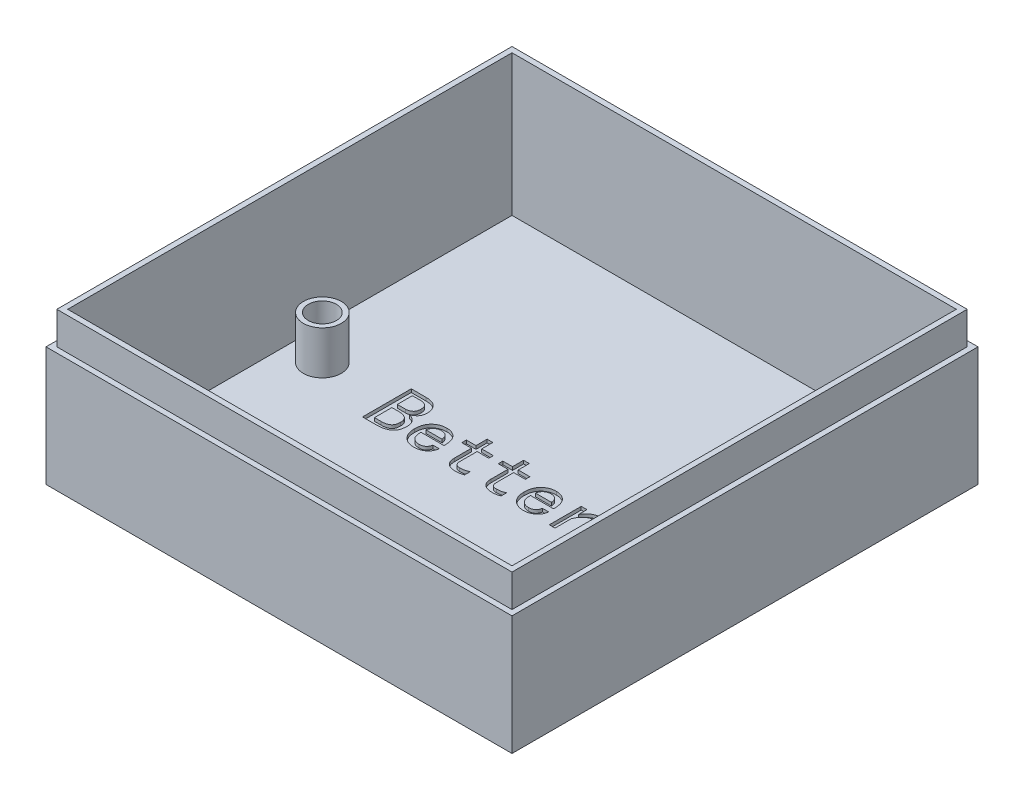
from build123d import *

# Parameters (mm, degrees)
SKETCH_1_W          = 43
SKETCH_1_H          = 43
EXTRUDE_1_DEPTH     = 14
SKETCH_2_W          = 41
SKETCH_2_H          = 41
CUT_EXTRUDE_1_DEPTH = 13
SKETCH_3_R          = 1.75
EXTRUDE_2_DEPTH     = 4
CUT_EXTRUDE_2_DEPTH = 0.3
SKETCH_6_W          = 43
SKETCH_6_H          = 43
SKETCH_6_W_2        = 42
SKETCH_6_H_2        = 42
CUT_EXTRUDE_3_DEPTH = 3
SKETCH_4_R          = 1.3
CUT_EXTRUDE_4_DEPTH = 6
SKETCH_9_R          = 1.55
CUT_EXTRUDE_5_DEPTH = 3


with BuildPart() as part:
    # 草图1 → 凸台-拉伸1 (new body)
    with BuildSketch(Plane(origin=(0, 0, 0), x_dir=(1, 0, 0), z_dir=(0, 1, 0))):
        with Locations((-5.509070295, -3.928571429)):
            Rectangle(SKETCH_1_W, SKETCH_1_H)
    extrude(amount=EXTRUDE_1_DEPTH)

    # 草图2 → 切除-拉伸1 (cut)
    with BuildSketch(Plane(origin=(0, 14, 0), x_dir=(1, 0, 0), z_dir=(0, 1, 0))):
        with Locations((-5.509070295, -3.928571429)):
            Rectangle(SKETCH_2_W, SKETCH_2_H)
    extrude(amount=-CUT_EXTRUDE_1_DEPTH, mode=Mode.SUBTRACT)

    # 草图3 → 凸台-拉伸2 (add)
    with BuildSketch(Plane(origin=(0, 1, 0), x_dir=(1, 0, 0), z_dir=(0, 1, 0))):
        with Locations((11.990929705, -20.428571429)):
            Circle(SKETCH_3_R)
        with Locations((11.990929705, 12.571428571)):
            Circle(SKETCH_3_R)
        with Locations((-23.009070295, -3.928571429)):
            Circle(SKETCH_3_R)
    extrude(amount=EXTRUDE_2_DEPTH)

    # 草图5 → 切除-拉伸2 (cut)
    with BuildSketch(Plane(origin=(0, 1, 0), x_dir=(1, 0, 0), z_dir=(0, 1, 0))):
        with BuildLine():
            add(Edge.make_bspline(
                [(-13.98754201, -5.087554235), (-13.98884355, -5.148684306), (-13.991349927, -5.266402496), (-14.010622519, -5.435807915), (-14.043382854, -5.590300694), (-14.089073364, -5.73054622), (-14.148335059, -5.855927811), (-14.221057431, -5.966926742), (-14.307645803, -6.062539103), (-14.40762424, -6.142749943), (-14.517215749, -6.210197735), (-14.634014643, -6.26911982), (-14.75832227, -6.3187478), (-14.889912901, -6.3597658), (-15.029189181, -6.390722201), (-15.175406971, -6.412856786), (-15.329053545, -6.426824846), (-15.433905332, -6.428700177), (-15.48754201, -6.429659498)],
                knots=[0, 0, 0, 0, 0.000183363, 0.000353102, 0.000510623, 0.000656409, 0.000794608, 0.000925445, 0.001053095, 0.001179894, 0.001308623, 0.001438516, 0.001571906, 0.001709706, 0.001851578, 0.001999485, 0.002153114, 0.002314006, 0.002314006, 0.002314006, 0.002314006], degree=3))
            Line((-15.48754201, -6.429659498), (-16.803331483, -6.429659498))
            Line((-16.803331483, -6.429659498), (-16.803331483, -1.929659498))
            Line((-16.803331483, -1.929659498), (-15.434910431, -1.929659498))
            add(Edge.make_bspline(
                [(-15.434910431, -1.929659498), (-15.381897455, -1.930334081), (-15.278841151, -1.931645459), (-15.1294118, -1.949270767), (-14.989442246, -1.974270777), (-14.860421537, -2.012845972), (-14.741487714, -2.06024041), (-14.632892999, -2.119075673), (-14.535272535, -2.189847869), (-14.44729276, -2.269646129), (-14.371091826, -2.357804477), (-14.303121887, -2.449246023), (-14.246336695, -2.545760096), (-14.19912939, -2.645676073), (-14.164325435, -2.750656088), (-14.137497473, -2.85902111), (-14.121712404, -2.97207885), (-14.119989651, -3.048845042), (-14.119120957, -3.087554235)],
                knots=[0, 0, 0, 0, 0.000158944, 0.000308985, 0.000450823, 0.000584976, 0.000712213, 0.000834338, 0.000954438, 0.001073107, 0.001189826, 0.001303477, 0.001414469, 0.001525224, 0.001634334, 0.001745676, 0.001859806, 0.001975893, 0.001975893, 0.001975893, 0.001975893], degree=3))
            add(Edge.make_bspline(
                [(-14.119120957, -3.087554235), (-14.120030688, -3.12557802), (-14.121798749, -3.199477121), (-14.130772974, -3.306499145), (-14.148851688, -3.405767422), (-14.172153149, -3.497609689), (-14.205402132, -3.580917708), (-14.242375823, -3.657742544), (-14.289158576, -3.72567003), (-14.358304515, -3.804134626), (-14.451666074, -3.887257938), (-14.565448223, -3.973217371), (-14.68213954, -4.041176882), (-14.763555436, -4.072332862), (-14.803331483, -4.087554235)],
                knots=[0, 0, 0, 0, 0.000114102, 0.000221756, 0.000321748, 0.000416551, 0.000505421, 0.000590418, 0.000671789, 0.000751925, 0.000903702, 0.001045809, 0.001179394, 0.001307, 0.001307, 0.001307, 0.001307], degree=3))
            add(Edge.make_bspline(
                [(-14.803331483, -4.087554235), (-14.751380449, -4.102485839), (-14.647372946, -4.132379351), (-14.501415957, -4.207326369), (-14.362451056, -4.300175579), (-14.256391256, -4.395344282), (-14.178464593, -4.480930903), (-14.127502096, -4.552062355), (-14.08334729, -4.627799805), (-14.048158958, -4.70972713), (-14.020974861, -4.796645961), (-14.001523002, -4.888993824), (-13.989672475, -4.986529706), (-13.988262122, -5.053407233), (-13.98754201, -5.087554235)],
                knots=[0, 0, 0, 0, 0.00016182, 0.000323968, 0.000489677, 0.000662244, 0.000749904, 0.000836468, 0.000924236, 0.001012414, 0.00110335, 0.001197019, 0.001295184, 0.001397597, 0.001397597, 0.001397597, 0.001397597], degree=3))
        make_face()
        with BuildLine():
            add(Edge.make_bspline(
                [(-14.724384115, -3.087554235), (-14.724810731, -3.059904139), (-14.725636764, -3.006366773), (-14.735798729, -2.929102668), (-14.75108149, -2.857558191), (-14.772591519, -2.791884816), (-14.799623677, -2.731545413), (-14.834562009, -2.677760194), (-14.874006233, -2.628163012), (-14.93746519, -2.573217584), (-15.024953535, -2.514738638), (-15.142551986, -2.464695487), (-15.271949658, -2.434693204), (-15.361969436, -2.43137707), (-15.408594641, -2.429659498)],
                knots=[0, 0, 0, 0, 8.2898e-05, 0.00016051, 0.000233349, 0.000302082, 0.0003675, 0.00043104, 0.000494062, 0.000556873, 0.000682032, 0.000808219, 0.000938255, 0.001077972, 0.001077972, 0.001077972, 0.001077972], degree=3))
            Line((-15.408594641, -2.429659498), (-16.198068325, -2.429659498))
            Line((-16.198068325, -2.429659498), (-16.198068325, -3.82439634))
            Line((-16.198068325, -3.82439634), (-15.434910431, -3.82439634))
            add(Edge.make_bspline(
                [(-15.434910431, -3.82439634), (-15.388253245, -3.82244374), (-15.296701688, -3.818612313), (-15.164836669, -3.785288076), (-15.042449003, -3.732128672), (-14.950014888, -3.669549828), (-14.884190113, -3.608193947), (-14.840390178, -3.554752289), (-14.80441103, -3.493788747), (-14.775381508, -3.425796976), (-14.7516355, -3.351152454), (-14.735682364, -3.2694033), (-14.725628728, -3.180724839), (-14.724809829, -3.119422836), (-14.724384115, -3.087554235)],
                knots=[0, 0, 0, 0, 0.000139788, 0.000274294, 0.000405222, 0.000538497, 0.000606758, 0.00067465, 0.000745021, 0.000818354, 0.000896034, 0.000979565, 0.001067824, 0.001163385, 0.001163385, 0.001163385, 0.001163385], degree=3))
        make_face(mode=Mode.SUBTRACT)
        with BuildLine():
            add(Edge.make_bspline(
                [(-14.619120957, -5.087554235), (-14.619616443, -5.053706), (-14.620573798, -4.988306074), (-14.635030186, -4.894381754), (-14.655793838, -4.8078191), (-14.686221789, -4.729157845), (-14.724980326, -4.658138656), (-14.773980418, -4.596311131), (-14.829700112, -4.540332715), (-14.917523183, -4.479679032), (-15.036309023, -4.417708641), (-15.188124834, -4.363444255), (-15.348360533, -4.330325538), (-15.458145117, -4.326392334), (-15.513857799, -4.32439634)],
                knots=[0, 0, 0, 0, 0.000101439, 0.000195996, 0.000284406, 0.000368028, 0.000448306, 0.000526096, 0.000603977, 0.000684308, 0.000845186, 0.001004569, 0.001166661, 0.001333672, 0.001333672, 0.001333672, 0.001333672], degree=3))
            Line((-15.513857799, -4.32439634), (-16.198068325, -4.32439634))
            Line((-16.198068325, -4.32439634), (-16.198068325, -5.929659498))
            Line((-16.198068325, -5.929659498), (-15.592805167, -5.929659498))
            add(Edge.make_bspline(
                [(-15.592805167, -5.929659498), (-15.554454315, -5.929115355), (-15.479920963, -5.928057835), (-15.371804737, -5.919428871), (-15.270737963, -5.90431485), (-15.17613803, -5.886037627), (-15.089227008, -5.858801722), (-15.00848334, -5.828728658), (-14.936224418, -5.789462415), (-14.868842498, -5.74742528), (-14.80952055, -5.695983247), (-14.758205349, -5.635384668), (-14.714431489, -5.56624811), (-14.679064414, -5.487770467), (-14.651953578, -5.400342712), (-14.633026472, -5.303947356), (-14.621078093, -5.198638944), (-14.619791272, -5.125600515), (-14.619120957, -5.087554235)],
                knots=[0, 0, 0, 0, 0.000115047, 0.000223589, 0.000325038, 0.000421569, 0.000512217, 0.000598009, 0.000679537, 0.000758479, 0.000835865, 0.000913989, 0.000995919, 0.001080535, 0.001171471, 0.001269911, 0.001374854, 0.001488955, 0.001488955, 0.001488955, 0.001488955], degree=3))
        make_face(mode=Mode.SUBTRACT)
        with BuildLine():
            add(Edge.make_bspline(
                [(-10.724384115, -5.429659498), (-10.729879058, -5.468441298), (-10.740638203, -5.544376384), (-10.768150301, -5.654910407), (-10.806299019, -5.759323749), (-10.854203364, -5.858347667), (-10.9120997, -5.951380333), (-10.979679412, -6.038928738), (-11.058172586, -6.119476365), (-11.144848994, -6.19457086), (-11.238302767, -6.261815828), (-11.336652365, -6.321055656), (-11.439438786, -6.370860885), (-11.546355042, -6.411782625), (-11.657644333, -6.443153579), (-11.772739427, -6.465324569), (-11.892005643, -6.479380126), (-11.972883141, -6.481312225), (-12.013857799, -6.482291077)],
                knots=[0, 0, 0, 0, 0.000117453, 0.000229975, 0.000340975, 0.000450389, 0.000559385, 0.000669146, 0.000781502, 0.000896206, 0.001012795, 0.001126459, 0.001240231, 0.001354993, 0.00146946, 0.001586634, 0.001706323, 0.001829227, 0.001829227, 0.001829227, 0.001829227], degree=3))
            add(Edge.make_bspline(
                [(-12.013857799, -6.482291077), (-12.065238238, -6.480833382), (-12.166383812, -6.47796382), (-12.314694183, -6.459735838), (-12.456011572, -6.427371853), (-12.589940667, -6.382107518), (-12.717722063, -6.326114374), (-12.837251569, -6.254608423), (-12.950659467, -6.171960651), (-13.055942029, -6.076301911), (-13.151120946, -5.969549316), (-13.234652556, -5.85269641), (-13.305432807, -5.726384928), (-13.361387049, -5.589854612), (-13.406693348, -5.444851417), (-13.438771583, -5.290167253), (-13.456987135, -5.126003678), (-13.45979141, -5.013525077), (-13.46122622, -4.955975287)],
                knots=[0, 0, 0, 0, 0.000154147, 0.000303448, 0.000447437, 0.000588292, 0.000727036, 0.000865108, 0.001005272, 0.001147412, 0.001291002, 0.001433535, 0.001577524, 0.001724323, 0.001875379, 0.002032699, 0.002197485, 0.002370135, 0.002370135, 0.002370135, 0.002370135], degree=3))
            add(Edge.make_bspline(
                [(-13.46122622, -4.955975287), (-13.459791438, -4.898425473), (-13.456987217, -4.785946824), (-13.438771278, -4.621783591), (-13.406694414, -4.467098211), (-13.361383282, -4.322099305), (-13.305446331, -4.185553641), (-13.234603315, -4.059297875), (-13.151444008, -3.942437003), (-13.055595067, -3.836606164), (-12.950694281, -3.740946735), (-12.837276333, -3.658246299), (-12.717476109, -3.587037823), (-12.590200175, -3.529589291), (-12.455974908, -3.484660428), (-12.314704447, -3.452191862), (-12.166381109, -3.433992779), (-12.065237327, -3.431119222), (-12.013857799, -3.429659498)],
                knots=[0, 0, 0, 0, 0.000172649, 0.000337436, 0.000494755, 0.000645812, 0.00079261, 0.000936599, 0.001079133, 0.001221996, 0.001364136, 0.001504301, 0.001642372, 0.001781517, 0.001922371, 0.00206636, 0.002215661, 0.002369808, 0.002369808, 0.002369808, 0.002369808], degree=3))
            add(Edge.make_bspline(
                [(-12.013857799, -3.429659498), (-11.968643101, -3.430789406), (-11.880176354, -3.433000176), (-11.75070258, -3.450132031), (-11.627440505, -3.476858712), (-11.510421215, -3.516105414), (-11.400216562, -3.567403431), (-11.294867145, -3.627826771), (-11.196053276, -3.700296404), (-11.104349976, -3.784650705), (-11.018756655, -3.880212648), (-10.947035733, -3.99252638), (-10.886919189, -4.118630902), (-10.835574806, -4.25801987), (-10.797377295, -4.412347453), (-10.770640345, -4.580941076), (-10.753942561, -4.763633614), (-10.751806934, -4.890310622), (-10.750699904, -4.955975287)],
                knots=[0, 0, 0, 0, 0.000135604, 0.000265321, 0.000391124, 0.000513485, 0.000634724, 0.000755255, 0.00087729, 0.001001466, 0.001128546, 0.001261014, 0.001399635, 0.001547024, 0.001705879, 0.001875727, 0.00205874, 0.002255707, 0.002255707, 0.002255707, 0.002255707], degree=3))
            Line((-10.750699904, -4.955975287), (-12.882278852, -4.955975287))
            add(Edge.make_bspline(
                [(-12.882278852, -4.955975287), (-12.881590367, -5.002460359), (-12.880263986, -5.092014827), (-12.868515859, -5.220997254), (-12.849395012, -5.339349124), (-12.822408451, -5.447140865), (-12.787203237, -5.544502831), (-12.744841971, -5.631647583), (-12.693765924, -5.707894836), (-12.634397559, -5.772547807), (-12.569750564, -5.828088525), (-12.500985259, -5.876077449), (-12.429000293, -5.917162717), (-12.352859357, -5.950645719), (-12.27324808, -5.976889), (-12.189997556, -5.99540427), (-12.103164721, -6.006265235), (-12.044103449, -6.007813824), (-12.013857799, -6.008606866)],
                knots=[0, 0, 0, 0, 0.000139431, 0.000268616, 0.00038815, 0.000498781, 0.000601454, 0.000698221, 0.00078878, 0.000875716, 0.000960713, 0.001043994, 0.001126925, 0.001208965, 0.001293108, 0.001377998, 0.001464436, 0.001555163, 0.001555163, 0.001555163, 0.001555163], degree=3))
            add(Edge.make_bspline(
                [(-12.013857799, -6.008606866), (-11.967563394, -6.007192374), (-11.878637602, -6.00447531), (-11.751995184, -5.976245901), (-11.637937385, -5.931822017), (-11.537693838, -5.867437936), (-11.452481277, -5.784410733), (-11.384593652, -5.682244164), (-11.331907509, -5.562989356), (-11.313112494, -5.47529568), (-11.303331483, -5.429659498)],
                knots=[0, 0, 0, 0, 0.000138679, 0.000266386, 0.000387106, 0.00050417, 0.00062134, 0.000741366, 0.000870117, 0.001009823, 0.001009823, 0.001009823, 0.001009823], degree=3))
            Line((-11.303331483, -5.429659498), (-10.724384115, -5.429659498))
        make_face()
        with BuildLine():
            add(Edge.make_bspline(
                [(-11.355963062, -4.534922656), (-11.360910307, -4.505314311), (-11.370468869, -4.448108092), (-11.388359715, -4.366069884), (-11.411965777, -4.2910856), (-11.440138391, -4.223477778), (-11.471167858, -4.161935483), (-11.507133394, -4.108195917), (-11.54781935, -4.061788077), (-11.606270728, -4.008297549), (-11.69092729, -3.955149158), (-11.804340139, -3.909060823), (-11.931316174, -3.881259229), (-12.020211062, -3.878476563), (-12.066489378, -3.877027919)],
                knots=[0, 0, 0, 0, 9.0054e-05, 0.000173994, 0.000251674, 0.000325523, 0.000393526, 0.000458134, 0.000518923, 0.000578257, 0.000695322, 0.000816407, 0.000944114, 0.001082793, 0.001082793, 0.001082793, 0.001082793], degree=3))
            add(Edge.make_bspline(
                [(-12.066489378, -3.877027919), (-12.10953117, -3.878538774), (-12.193928146, -3.881501282), (-12.317247563, -3.910262922), (-12.433441181, -3.956245179), (-12.52488289, -4.008772785), (-12.591920927, -4.061811532), (-12.640423452, -4.108017873), (-12.685039134, -4.161743671), (-12.726200629, -4.222946961), (-12.763832649, -4.290852297), (-12.798143881, -4.365862394), (-12.829237283, -4.447641424), (-12.846876228, -4.505246809), (-12.855963062, -4.534922656)],
                knots=[0, 0, 0, 0, 0.000128954, 0.000252854, 0.000377557, 0.000502929, 0.00056747, 0.000633647, 0.00070353, 0.000776519, 0.00085462, 0.000936171, 0.001023782, 0.001116871, 0.001116871, 0.001116871, 0.001116871], degree=3))
            Line((-12.855963062, -4.534922656), (-11.355963062, -4.534922656))
        make_face(mode=Mode.SUBTRACT)
        with BuildLine():
            add(Edge.make_bspline(
                [(-7.46122622, -6.350712129), (-7.508102545, -6.367961103), (-7.607352246, -6.404481788), (-7.740082961, -6.439979739), (-7.861372175, -6.461511521), (-7.969037327, -6.474314031), (-8.091765512, -6.480231783), (-8.178571296, -6.481579698), (-8.224384115, -6.482291077)],
                knots=[0, 0, 0, 0, 0.000149812, 0.000317193, 0.000411256, 0.000519215, 0.000642211, 0.000779669, 0.000779669, 0.000779669, 0.000779669], degree=3))
            add(Edge.make_bspline(
                [(-8.224384115, -6.482291077), (-8.263089908, -6.481697704), (-8.338448556, -6.480542432), (-8.44851267, -6.467035822), (-8.553120722, -6.447412057), (-8.651545002, -6.417384874), (-8.745364191, -6.382133415), (-8.832063674, -6.335574719), (-8.913456237, -6.281898722), (-8.988685172, -6.220307631), (-9.057100619, -6.151655629), (-9.115604062, -6.07487403), (-9.165867783, -5.992353113), (-9.207120353, -5.90320678), (-9.238076396, -5.806864535), (-9.260236281, -5.704351004), (-9.274217692, -5.595407338), (-9.276066343, -5.520670953), (-9.277015694, -5.482291077)],
                knots=[0, 0, 0, 0, 0.00011605, 0.000225945, 0.000332223, 0.000434914, 0.000534281, 0.000632379, 0.000729425, 0.000826392, 0.00092357, 0.001019484, 0.001115263, 0.001212948, 0.001313428, 0.001418194, 0.001527238, 0.001642351, 0.001642351, 0.001642351, 0.001642351], degree=3))
            Line((-9.277015694, -5.482291077), (-9.277015694, -3.903343708))
            Line((-9.277015694, -3.903343708), (-10.171752536, -3.903343708))
            Line((-10.171752536, -3.903343708), (-10.171752536, -3.482291077))
            Line((-10.171752536, -3.482291077), (-9.277015694, -3.482291077))
            Line((-9.277015694, -3.482291077), (-9.277015694, -2.455975287))
            Line((-9.277015694, -2.455975287), (-8.750699904, -2.455975287))
            Line((-8.750699904, -2.455975287), (-8.750699904, -3.482291077))
            Line((-8.750699904, -3.482291077), (-7.671752536, -3.482291077))
            Line((-7.671752536, -3.482291077), (-7.671752536, -3.903343708))
            Line((-7.671752536, -3.903343708), (-8.750699904, -3.903343708))
            Line((-8.750699904, -3.903343708), (-8.750699904, -5.508606866))
            add(Edge.make_bspline(
                [(-8.750699904, -5.508606866), (-8.74939981, -5.542486404), (-8.746888838, -5.607920586), (-8.727254056, -5.702218214), (-8.69345546, -5.787839418), (-8.655768675, -5.853431607), (-8.616996348, -5.899603397), (-8.581297736, -5.929178633), (-8.5397788, -5.953148813), (-8.493363083, -5.974389671), (-8.440631236, -5.989042736), (-8.382430118, -6.0012007), (-8.318425102, -6.007738943), (-8.273779486, -6.008311093), (-8.250699904, -6.008606866)],
                knots=[0, 0, 0, 0, 0.000101594, 0.000196216, 0.000287257, 0.000376851, 0.000421781, 0.000467455, 0.000515094, 0.000565267, 0.00062016, 0.000678843, 0.000743531, 0.000812759, 0.000812759, 0.000812759, 0.000812759], degree=3))
            add(Edge.make_bspline(
                [(-8.250699904, -6.008606866), (-8.204529417, -6.008357317), (-8.116596384, -6.007882044), (-7.991489759, -5.995925554), (-7.879025715, -5.982148788), (-7.779258448, -5.957863631), (-7.68954592, -5.928822213), (-7.607021727, -5.898146906), (-7.530854234, -5.864103323), (-7.484099066, -5.837440108), (-7.46122622, -5.82439634)],
                knots=[0, 0, 0, 0, 0.000138432, 0.000263649, 0.000376814, 0.000477996, 0.000571084, 0.000659607, 0.000742045, 0.000820998, 0.000820998, 0.000820998, 0.000820998], degree=3))
            Line((-7.46122622, -5.82439634), (-7.46122622, -6.350712129))
        make_face()
        with BuildLine():
            add(Edge.make_bspline(
                [(-4.092805167, -6.350712129), (-4.139681492, -6.367961103), (-4.238931193, -6.404481788), (-4.371661909, -6.439979739), (-4.492951122, -6.461511521), (-4.600616274, -6.474314031), (-4.72334446, -6.480231783), (-4.810150244, -6.481579698), (-4.855963062, -6.482291077)],
                knots=[0, 0, 0, 0, 0.000149812, 0.000317193, 0.000411256, 0.000519215, 0.000642211, 0.000779669, 0.000779669, 0.000779669, 0.000779669], degree=3))
            add(Edge.make_bspline(
                [(-4.855963062, -6.482291077), (-4.894668855, -6.481697704), (-4.970027504, -6.480542432), (-5.080091617, -6.467035822), (-5.18469967, -6.447412057), (-5.28312395, -6.417384874), (-5.376943138, -6.382133415), (-5.463642621, -6.335574719), (-5.545035185, -6.281898722), (-5.620264119, -6.220307631), (-5.688679566, -6.151655629), (-5.747183009, -6.07487403), (-5.79744673, -5.992353113), (-5.8386993, -5.90320678), (-5.869655343, -5.806864535), (-5.891815228, -5.704351004), (-5.90579664, -5.595407338), (-5.907645291, -5.520670953), (-5.908594641, -5.482291077)],
                knots=[0, 0, 0, 0, 0.00011605, 0.000225945, 0.000332223, 0.000434914, 0.000534281, 0.000632379, 0.000729425, 0.000826392, 0.00092357, 0.001019484, 0.001115263, 0.001212948, 0.001313428, 0.001418194, 0.001527238, 0.001642351, 0.001642351, 0.001642351, 0.001642351], degree=3))
            Line((-5.908594641, -5.482291077), (-5.908594641, -3.903343708))
            Line((-5.908594641, -3.903343708), (-6.803331483, -3.903343708))
            Line((-6.803331483, -3.903343708), (-6.803331483, -3.482291077))
            Line((-6.803331483, -3.482291077), (-5.908594641, -3.482291077))
            Line((-5.908594641, -3.482291077), (-5.908594641, -2.455975287))
            Line((-5.908594641, -2.455975287), (-5.382278852, -2.455975287))
            Line((-5.382278852, -2.455975287), (-5.382278852, -3.482291077))
            Line((-5.382278852, -3.482291077), (-4.303331483, -3.482291077))
            Line((-4.303331483, -3.482291077), (-4.303331483, -3.903343708))
            Line((-4.303331483, -3.903343708), (-5.382278852, -3.903343708))
            Line((-5.382278852, -3.903343708), (-5.382278852, -5.508606866))
            add(Edge.make_bspline(
                [(-5.382278852, -5.508606866), (-5.380978758, -5.542486404), (-5.378467785, -5.607920586), (-5.358833004, -5.702218214), (-5.325034408, -5.787839418), (-5.287347622, -5.853431607), (-5.248575295, -5.899603397), (-5.212876683, -5.929178633), (-5.171357747, -5.953148813), (-5.12494203, -5.974389671), (-5.072210183, -5.989042736), (-5.014009066, -6.0012007), (-4.95000405, -6.007738943), (-4.905358433, -6.008311093), (-4.882278852, -6.008606866)],
                knots=[0, 0, 0, 0, 0.000101594, 0.000196216, 0.000287257, 0.000376851, 0.000421781, 0.000467455, 0.000515094, 0.000565267, 0.00062016, 0.000678843, 0.000743531, 0.000812759, 0.000812759, 0.000812759, 0.000812759], degree=3))
            add(Edge.make_bspline(
                [(-4.882278852, -6.008606866), (-4.836108365, -6.008357317), (-4.748175331, -6.007882044), (-4.623068706, -5.995925554), (-4.510604662, -5.982148788), (-4.410837396, -5.957863631), (-4.321124868, -5.928822213), (-4.238600675, -5.898146906), (-4.162433181, -5.864103323), (-4.115678013, -5.837440108), (-4.092805167, -5.82439634)],
                knots=[0, 0, 0, 0, 0.000138432, 0.000263649, 0.000376814, 0.000477996, 0.000571084, 0.000659607, 0.000742045, 0.000820998, 0.000820998, 0.000820998, 0.000820998], degree=3))
            Line((-4.092805167, -5.82439634), (-4.092805167, -6.350712129))
        make_face()
        with BuildLine():
            add(Edge.make_bspline(
                [(-0.619120957, -5.429659498), (-0.6246159, -5.468441298), (-0.635375045, -5.544376384), (-0.662887143, -5.654910407), (-0.701035861, -5.759323749), (-0.748940206, -5.858347667), (-0.806836542, -5.951380333), (-0.874416254, -6.038928738), (-0.952909428, -6.119476365), (-1.039585837, -6.19457086), (-1.133039609, -6.261815828), (-1.231389207, -6.321055656), (-1.334175628, -6.370860885), (-1.441091884, -6.411782625), (-1.552381175, -6.443153579), (-1.667476269, -6.465324569), (-1.786742485, -6.479380126), (-1.867619983, -6.481312225), (-1.908594641, -6.482291077)],
                knots=[0, 0, 0, 0, 0.000117453, 0.000229975, 0.000340975, 0.000450389, 0.000559385, 0.000669146, 0.000781502, 0.000896206, 0.001012795, 0.001126459, 0.001240231, 0.001354993, 0.00146946, 0.001586634, 0.001706323, 0.001829227, 0.001829227, 0.001829227, 0.001829227], degree=3))
            add(Edge.make_bspline(
                [(-1.908594641, -6.482291077), (-1.95997508, -6.480833382), (-2.061120655, -6.47796382), (-2.209431025, -6.459735838), (-2.350748414, -6.427371853), (-2.484677509, -6.382107518), (-2.612458905, -6.326114374), (-2.731988411, -6.254608423), (-2.845396309, -6.171960651), (-2.950678871, -6.076301911), (-3.045857789, -5.969549316), (-3.129389399, -5.85269641), (-3.200169649, -5.726384928), (-3.256123891, -5.589854612), (-3.30143019, -5.444851417), (-3.333508425, -5.290167253), (-3.351723977, -5.126003678), (-3.354528252, -5.013525077), (-3.355963062, -4.955975287)],
                knots=[0, 0, 0, 0, 0.000154147, 0.000303448, 0.000447437, 0.000588292, 0.000727036, 0.000865108, 0.001005272, 0.001147412, 0.001291002, 0.001433535, 0.001577524, 0.001724323, 0.001875379, 0.002032699, 0.002197485, 0.002370135, 0.002370135, 0.002370135, 0.002370135], degree=3))
            add(Edge.make_bspline(
                [(-3.355963062, -4.955975287), (-3.35452828, -4.898425473), (-3.351724059, -4.785946824), (-3.333508121, -4.621783591), (-3.301431256, -4.467098211), (-3.256120125, -4.322099305), (-3.200183174, -4.185553641), (-3.129340157, -4.059297875), (-3.04618085, -3.942437003), (-2.950331909, -3.836606164), (-2.845431123, -3.740946735), (-2.732013175, -3.658246299), (-2.612212951, -3.587037823), (-2.484937017, -3.529589291), (-2.35071175, -3.484660428), (-2.209441289, -3.452191862), (-2.061117951, -3.433992779), (-1.959974169, -3.431119222), (-1.908594641, -3.429659498)],
                knots=[0, 0, 0, 0, 0.000172649, 0.000337436, 0.000494755, 0.000645812, 0.00079261, 0.000936599, 0.001079133, 0.001221996, 0.001364136, 0.001504301, 0.001642372, 0.001781517, 0.001922371, 0.00206636, 0.002215661, 0.002369808, 0.002369808, 0.002369808, 0.002369808], degree=3))
            add(Edge.make_bspline(
                [(-1.908594641, -3.429659498), (-1.863379943, -3.430789406), (-1.774913196, -3.433000176), (-1.645439422, -3.450132031), (-1.522177347, -3.476858712), (-1.405158057, -3.516105414), (-1.294953404, -3.567403431), (-1.189603987, -3.627826771), (-1.090790118, -3.700296404), (-0.999086818, -3.784650705), (-0.913493497, -3.880212648), (-0.841772575, -3.99252638), (-0.781656032, -4.118630902), (-0.730311648, -4.25801987), (-0.692114137, -4.412347453), (-0.665377188, -4.580941076), (-0.648679403, -4.763633614), (-0.646543776, -4.890310622), (-0.645436746, -4.955975287)],
                knots=[0, 0, 0, 0, 0.000135604, 0.000265321, 0.000391124, 0.000513485, 0.000634724, 0.000755255, 0.00087729, 0.001001466, 0.001128546, 0.001261014, 0.001399635, 0.001547024, 0.001705879, 0.001875727, 0.00205874, 0.002255707, 0.002255707, 0.002255707, 0.002255707], degree=3))
            Line((-0.645436746, -4.955975287), (-2.777015694, -4.955975287))
            add(Edge.make_bspline(
                [(-2.777015694, -4.955975287), (-2.776327209, -5.002460359), (-2.775000828, -5.092014827), (-2.763252701, -5.220997254), (-2.744131854, -5.339349124), (-2.717145293, -5.447140865), (-2.681940079, -5.544502831), (-2.639578813, -5.631647583), (-2.588502766, -5.707894836), (-2.529134401, -5.772547807), (-2.464487406, -5.828088525), (-2.395722101, -5.876077449), (-2.323737135, -5.917162717), (-2.247596199, -5.950645719), (-2.167984922, -5.976889), (-2.084734398, -5.99540427), (-1.997901564, -6.006265235), (-1.938840291, -6.007813824), (-1.908594641, -6.008606866)],
                knots=[0, 0, 0, 0, 0.000139431, 0.000268616, 0.00038815, 0.000498781, 0.000601454, 0.000698221, 0.00078878, 0.000875716, 0.000960713, 0.001043994, 0.001126925, 0.001208965, 0.001293108, 0.001377998, 0.001464436, 0.001555163, 0.001555163, 0.001555163, 0.001555163], degree=3))
            add(Edge.make_bspline(
                [(-1.908594641, -6.008606866), (-1.862300236, -6.007192374), (-1.773374444, -6.00447531), (-1.646732026, -5.976245901), (-1.532674227, -5.931822017), (-1.432430681, -5.867437936), (-1.347218119, -5.784410733), (-1.279330494, -5.682244164), (-1.226644351, -5.562989356), (-1.207849336, -5.47529568), (-1.198068325, -5.429659498)],
                knots=[0, 0, 0, 0, 0.000138679, 0.000266386, 0.000387106, 0.00050417, 0.00062134, 0.000741366, 0.000870117, 0.001009823, 0.001009823, 0.001009823, 0.001009823], degree=3))
            Line((-1.198068325, -5.429659498), (-0.619120957, -5.429659498))
        make_face()
        with BuildLine():
            add(Edge.make_bspline(
                [(-1.250699904, -4.534922656), (-1.255647149, -4.505314311), (-1.265205711, -4.448108092), (-1.283096557, -4.366069884), (-1.30670262, -4.2910856), (-1.334875233, -4.223477778), (-1.3659047, -4.161935483), (-1.401870237, -4.108195917), (-1.442556192, -4.061788077), (-1.50100757, -4.008297549), (-1.585664132, -3.955149158), (-1.699076981, -3.909060823), (-1.826053016, -3.881259229), (-1.914947904, -3.878476563), (-1.96122622, -3.877027919)],
                knots=[0, 0, 0, 0, 9.0054e-05, 0.000173994, 0.000251674, 0.000325523, 0.000393526, 0.000458134, 0.000518923, 0.000578257, 0.000695322, 0.000816407, 0.000944114, 0.001082793, 0.001082793, 0.001082793, 0.001082793], degree=3))
            add(Edge.make_bspline(
                [(-1.96122622, -3.877027919), (-2.004268012, -3.878538774), (-2.088664989, -3.881501282), (-2.211984405, -3.910262922), (-2.328178023, -3.956245179), (-2.419619732, -4.008772785), (-2.486657769, -4.061811532), (-2.535160294, -4.108017873), (-2.579775976, -4.161743671), (-2.620937471, -4.222946961), (-2.658569491, -4.290852297), (-2.692880723, -4.365862394), (-2.723974125, -4.447641424), (-2.74161307, -4.505246809), (-2.750699904, -4.534922656)],
                knots=[0, 0, 0, 0, 0.000128954, 0.000252854, 0.000377557, 0.000502929, 0.00056747, 0.000633647, 0.00070353, 0.000776519, 0.00085462, 0.000936171, 0.001023782, 0.001116871, 0.001116871, 0.001116871, 0.001116871], degree=3))
            Line((-2.750699904, -4.534922656), (-1.250699904, -4.534922656))
        make_face(mode=Mode.SUBTRACT)
        with BuildLine():
            add(Edge.make_bspline(
                [(2.380879043, -4.008606866), (2.340002538, -4.003157215), (2.260420704, -3.992547374), (2.142459281, -3.986585638), (2.029579724, -3.990090097), (1.92139173, -4.004186121), (1.818002774, -4.02590944), (1.719502488, -4.058721024), (1.625789215, -4.100271999), (1.537232278, -4.15280315), (1.453005085, -4.214850216), (1.371947845, -4.286093388), (1.294534834, -4.367805461), (1.220508416, -4.459884457), (1.149183464, -4.562286224), (1.082569901, -4.675880417), (1.017715377, -4.798492441), (0.979438811, -4.885220963), (0.959826411, -4.929659498)],
                knots=[0, 0, 0, 0, 0.000123674, 0.000240779, 0.000353907, 0.000461984, 0.000567702, 0.000670338, 0.000772863, 0.000874662, 0.000978567, 0.001086301, 0.001197984, 0.001315801, 0.001440443, 0.001571993, 0.001710627, 0.001856306, 0.001856306, 0.001856306, 0.001856306], degree=3))
            Line((0.959826411, -4.929659498), (0.959826411, -6.429659498))
            Line((0.959826411, -6.429659498), (0.433510622, -6.429659498))
            Line((0.433510622, -6.429659498), (0.433510622, -3.482291077))
            Line((0.433510622, -3.482291077), (0.959826411, -3.482291077))
            Line((0.959826411, -3.482291077), (0.959826411, -4.245448971))
            add(Edge.make_bspline(
                [(0.959826411, -4.245448971), (0.97999055, -4.211475578), (1.019748174, -4.144490251), (1.083640029, -4.048835786), (1.152339123, -3.960846947), (1.224133457, -3.879589246), (1.301006997, -3.80632468), (1.380334562, -3.739015199), (1.463818226, -3.679100536), (1.551080895, -3.626506439), (1.641669547, -3.579336307), (1.736745947, -3.539626909), (1.834932212, -3.50532186), (1.937292251, -3.478026156), (2.043120216, -3.456774787), (2.15246142, -3.44135148), (2.26534415, -3.430969681), (2.34186872, -3.430101881), (2.380879043, -3.429659498)],
                knots=[0, 0, 0, 0, 0.000118512, 0.000233671, 0.000344799, 0.000453179, 0.000558645, 0.000663097, 0.000765069, 0.000866532, 0.000968536, 0.001071177, 0.001175361, 0.001280335, 0.001388715, 0.001498985, 0.001611494, 0.001728489, 0.001728489, 0.001728489, 0.001728489], degree=3))
            Line((2.380879043, -3.429659498), (2.380879043, -4.008606866))
        make_face()
        Polygon((6.275615885, -4.32439634), (4.986142201, -4.32439634), (4.986142201, -5.613870024), (4.53877378, -5.613870024), (4.53877378, -4.32439634), (3.249300096, -4.32439634), (3.249300096, -3.903343708), (4.53877378, -3.903343708), (4.53877378, -2.613870024), (4.986142201, -2.613870024), (4.986142201, -3.903343708), (6.275615885, -3.903343708), align=None)
        Polygon((9.644036938, -4.32439634), (8.354563254, -4.32439634), (8.354563254, -5.613870024), (7.907194833, -5.613870024), (7.907194833, -4.32439634), (6.617721148, -4.32439634), (6.617721148, -3.903343708), (7.907194833, -3.903343708), (7.907194833, -2.613870024), (8.354563254, -2.613870024), (8.354563254, -3.903343708), (9.644036938, -3.903343708), align=None)
    extrude(amount=-CUT_EXTRUDE_2_DEPTH, mode=Mode.SUBTRACT)

    # 草图6 → 切除-拉伸3 (cut)
    with BuildSketch(Plane(origin=(0, 14, 0), x_dir=(1, 0, 0), z_dir=(0, 1, 0))):
        with Locations((-5.509070295, -3.928571429)):
            Rectangle(SKETCH_6_W, SKETCH_6_H)
        with Locations((-5.509070295, -3.928571429)):
            Rectangle(SKETCH_6_W_2, SKETCH_6_H_2, mode=Mode.SUBTRACT)
    extrude(amount=-CUT_EXTRUDE_3_DEPTH, mode=Mode.SUBTRACT)

    # 草图4 → 切除-拉伸4 (cut, through all)
    with BuildSketch(Plane(origin=(0, 5, 0), x_dir=(1, 0, 0), z_dir=(0, 1, 0))):
        with Locations((-23.009070295, -3.928571429)):
            Circle(SKETCH_4_R)
        with Locations((11.990929705, 12.571428571)):
            Circle(SKETCH_4_R)
        with Locations((11.990929705, -20.428571429)):
            Circle(SKETCH_4_R)
    extrude(amount=-CUT_EXTRUDE_4_DEPTH, mode=Mode.SUBTRACT)

    # 草图9 → 切除-拉伸5 (cut)
    with BuildSketch(Plane.XZ):
        with Locations((-23.009070295, 3.928571429)):
            Circle(SKETCH_9_R)
        with Locations((11.990929705, -12.571428571)):
            Circle(SKETCH_9_R)
        with Locations((11.990929705, 20.428571429)):
            Circle(SKETCH_9_R)
    extrude(amount=-CUT_EXTRUDE_5_DEPTH, mode=Mode.SUBTRACT)


solid = part.part
